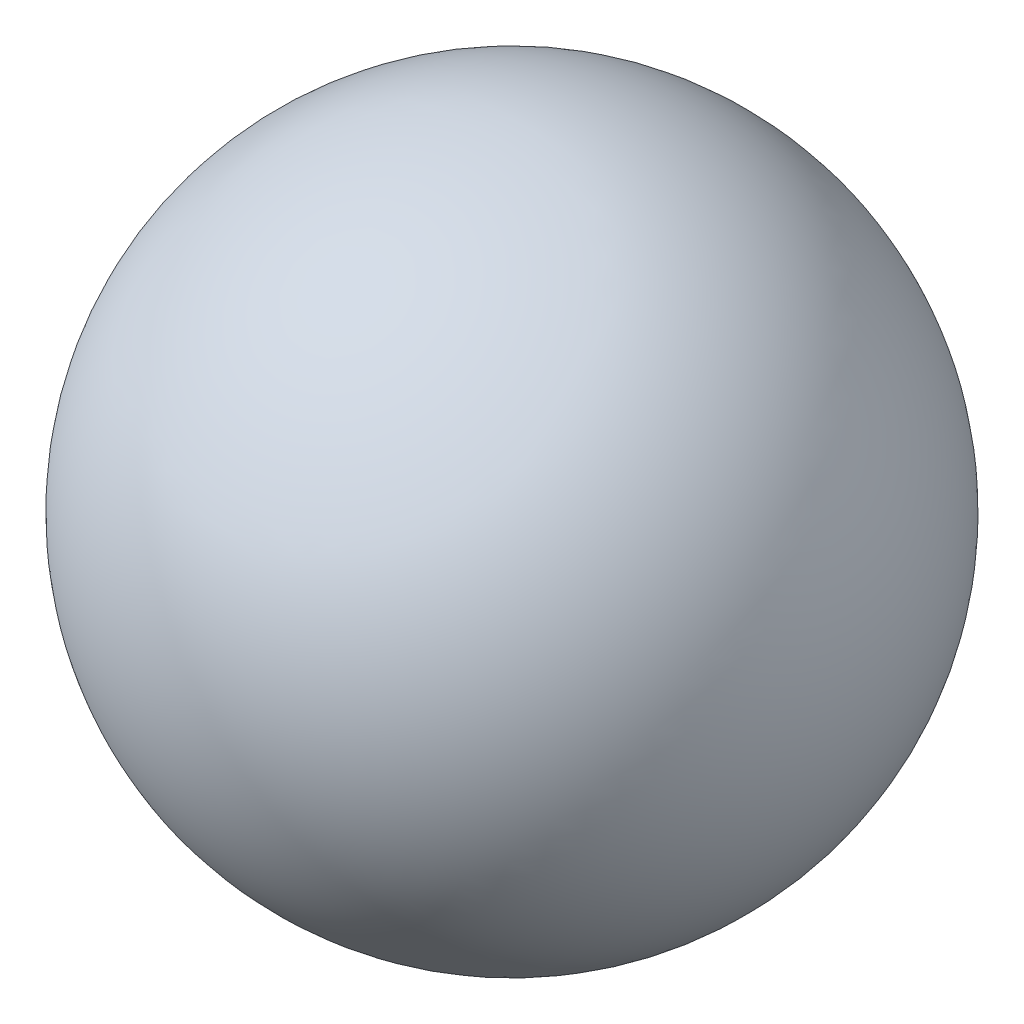
from build123d import *


with BuildPart() as part:
    # 草图1 one side → 旋转2 (revolve)
    with BuildSketch(Plane(origin=(0, 0, 0), x_dir=(1, 0, 0), z_dir=(0, 1, 0))):
        with BuildLine():
            ThreePointArc((0, -1), (0.707106781, -0.707106781), (1, 0))
            ThreePointArc((1, 0), (0.707106781, 0.707106781), (0, 1))
            Line((0, 1), (0, -1))
        make_face()
    revolve(axis=Axis((0, 0, -6.936103092), (0, 0, 1)))


solid = part.part
